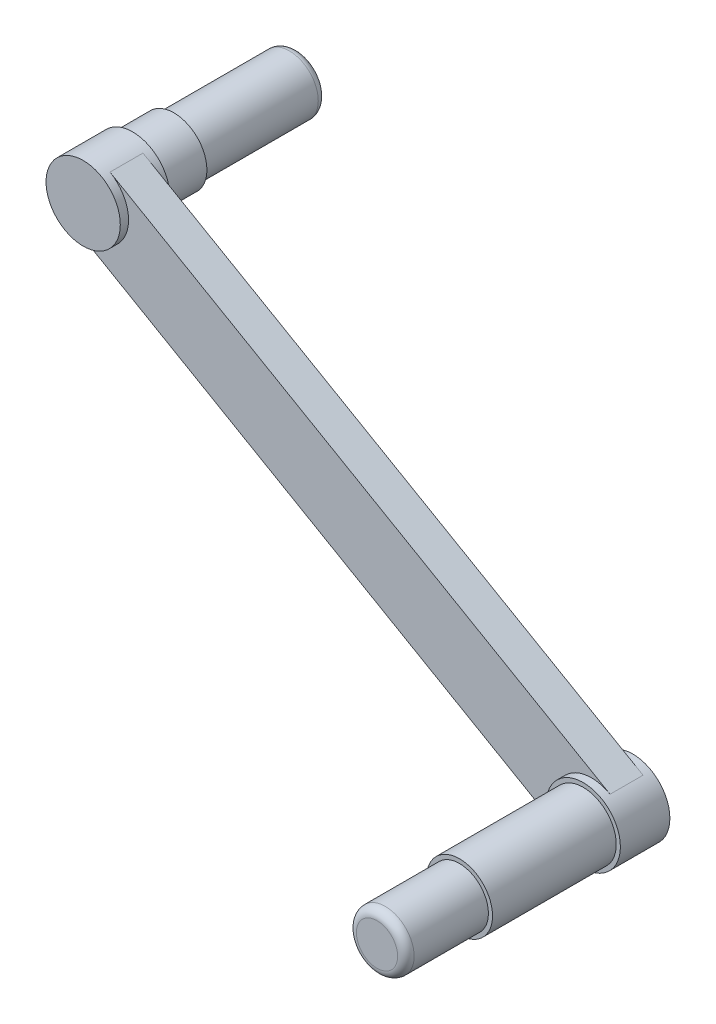
from build123d import *

# Parameters (mm, degrees)
SKETCH1_R                = 3.5
BOSS_EXTRUDE1_DEPTH      = 15
SKETCH2_R                = 4
BOSS_EXTRUDE2_DEPTH      = 5
SKETCH3_R                = 4.5
BOSS_EXTRUDE3_DEPTH      = 5
BOSS_EXTRUDE4_DEPTH      = 4
SKETCH6_R                = 4.5
BOSS_EXTRUDE5_DEPTH      = 1
BOSS_EXTRUDE5_DEPTH_BACK = 5
SKETCH7_R                = 4
BOSS_EXTRUDE6_DEPTH      = 15
SKETCH8_R                = 3.5
BOSS_EXTRUDE7_DEPTH      = 10
FILLET3_R                = 1


with BuildPart() as part:
    # Sketch1 → Boss-Extrude1 (new body)
    with BuildSketch(Plane.XY):
        Circle(SKETCH1_R)
    extrude(amount=-BOSS_EXTRUDE1_DEPTH)

    # Sketch2 → Boss-Extrude2 (add)
    with BuildSketch(Plane.XY):
        Circle(SKETCH2_R)
    extrude(amount=BOSS_EXTRUDE2_DEPTH)

    # Sketch3 → Boss-Extrude3 (add)
    with BuildSketch(Plane.XY.offset(5)):
        Circle(SKETCH3_R)
    extrude(amount=BOSS_EXTRUDE3_DEPTH)

    # Sketch5 → Boss-Extrude4 (add)
    with BuildSketch(Plane.XY.offset(10)):
        with BuildLine():
            Line((0, 0), (-2.25, -3.897114317))
            Line((-2.25, -3.897114317), (58.371778036, -38.897114185))
            ThreePointArc((58.371778036, -38.897114185), (64.518892287, -37.249999982), (62.871778265, -31.102885683))
            Line((62.871778265, -31.102885683), (2.25, 3.897114317))
            Line((2.25, 3.897114317), (0, 0))
        make_face()
    extrude(amount=-BOSS_EXTRUDE4_DEPTH)

    # Sketch6 → Boss-Extrude5 (add, two sides)
    with BuildSketch(Plane.XY.offset(10)) as boss_extrude5_sk:
        Circle(SKETCH6_R)
        with Locations((60.621778036, -34.999999868)):
            Circle(SKETCH6_R)
    extrude(amount=BOSS_EXTRUDE5_DEPTH)
    extrude(boss_extrude5_sk.sketch, amount=-BOSS_EXTRUDE5_DEPTH_BACK)

    # Sketch7 → Boss-Extrude6 (add)
    with BuildSketch(Plane.XY.offset(11)):
        with Locations((60.621778036, -34.999999868)):
            Circle(SKETCH7_R)
    extrude(amount=BOSS_EXTRUDE6_DEPTH)

    # Sketch8 → Boss-Extrude7 (add)
    with BuildSketch(Plane.XY.offset(26)):
        with Locations((60.621778036, -34.999999868)):
            Circle(SKETCH8_R)
    extrude(amount=BOSS_EXTRUDE7_DEPTH)

    # Fillet3
    fillet3_edges = [part.edges().sort_by_distance(p)[0] for p in [
        (-3.5, 0, -15),
        (57.121778036, -34.999999868, 36),
    ]]
    fillet(fillet3_edges, radius=FILLET3_R)


solid = part.part
